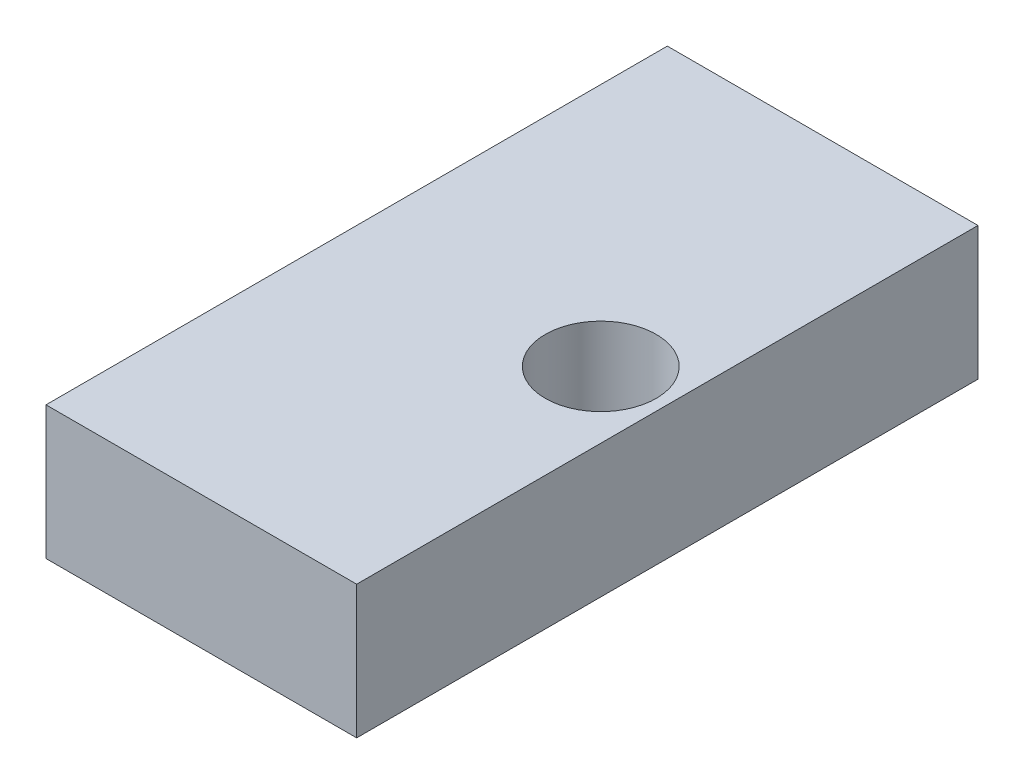
from build123d import *

# Parameters (mm, degrees)
SKETCH1_W           = 44.45
SKETCH1_H           = 19.05
BOSS_EXTRUDE1_DEPTH = 88.9
SKETCH3_R           = 7.9375
CUT_EXTRUDE1_DEPTH  = 20.05


with BuildPart() as part:
    # Sketch1 → Boss-Extrude1 (new body)
    with BuildSketch(Plane.XY):
        Rectangle(SKETCH1_W, SKETCH1_H)
    extrude(amount=-BOSS_EXTRUDE1_DEPTH)

    # Sketch3 → Cut-Extrude1 (cut, through all)
    with BuildSketch(Plane(origin=(0, 9.525, 0), x_dir=(1, 0, 0), z_dir=(0, 1, 0))):
        with Locations((12.7, 44.45)):
            Circle(SKETCH3_R)
    extrude(amount=-CUT_EXTRUDE1_DEPTH, mode=Mode.SUBTRACT)


solid = part.part
